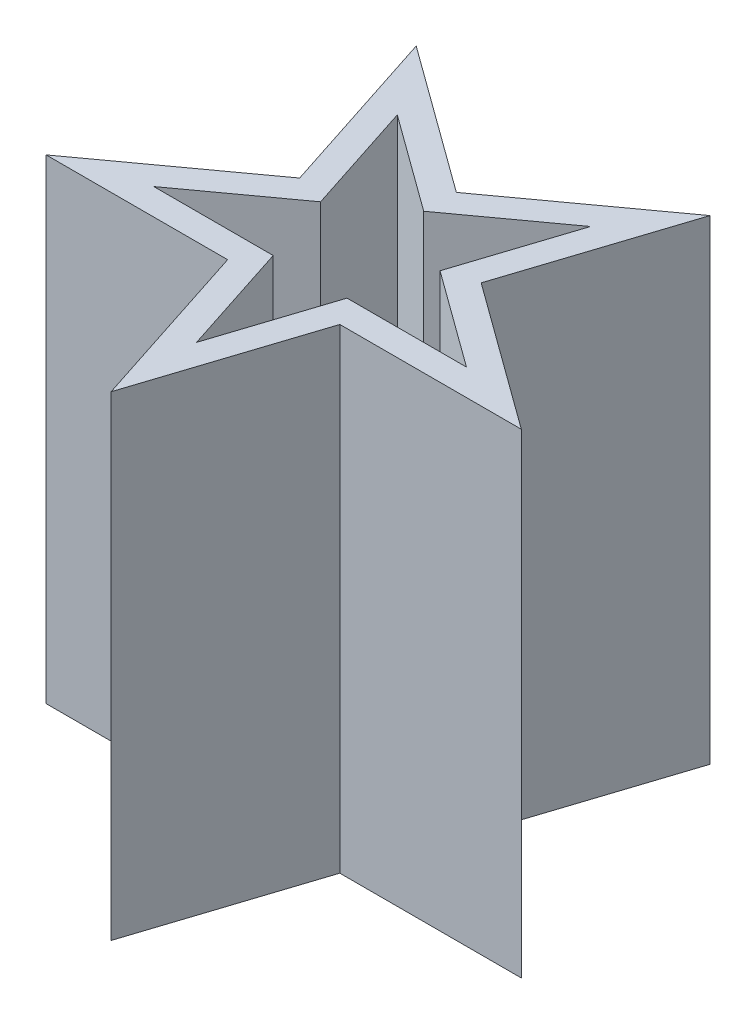
from build123d import *

# Parameters (mm, degrees)
BOSS_EXTRUDE1_DEPTH = 18
SHELL2_T            = -1


with BuildPart() as part:
    # Sketch1 → Boss-Extrude1 (new body)
    with BuildSketch(Plane(origin=(0, 0, 0), x_dir=(1, 0, 0), z_dir=(0, 1, 0))):
        Polygon((2.124611797, -2.924277266), (0, -9.463160018), (-2.124611797, -2.924277266), (-9, -2.924277266), (-3.437694101, 1.116974523), (-5.562305899, 7.655857275), (0, 3.614605486), (5.562305899, 7.655857275), (3.437694101, 1.116974523), (9, -2.924277266), align=None)
    extrude(amount=BOSS_EXTRUDE1_DEPTH)

    # Shell2
    shell2_openings = [part.faces().sort_by_distance(p)[0] for p in [
        (0, 18, 0),
    ]]
    offset(amount=SHELL2_T, openings=shell2_openings, kind=Kind.INTERSECTION)


solid = part.part
